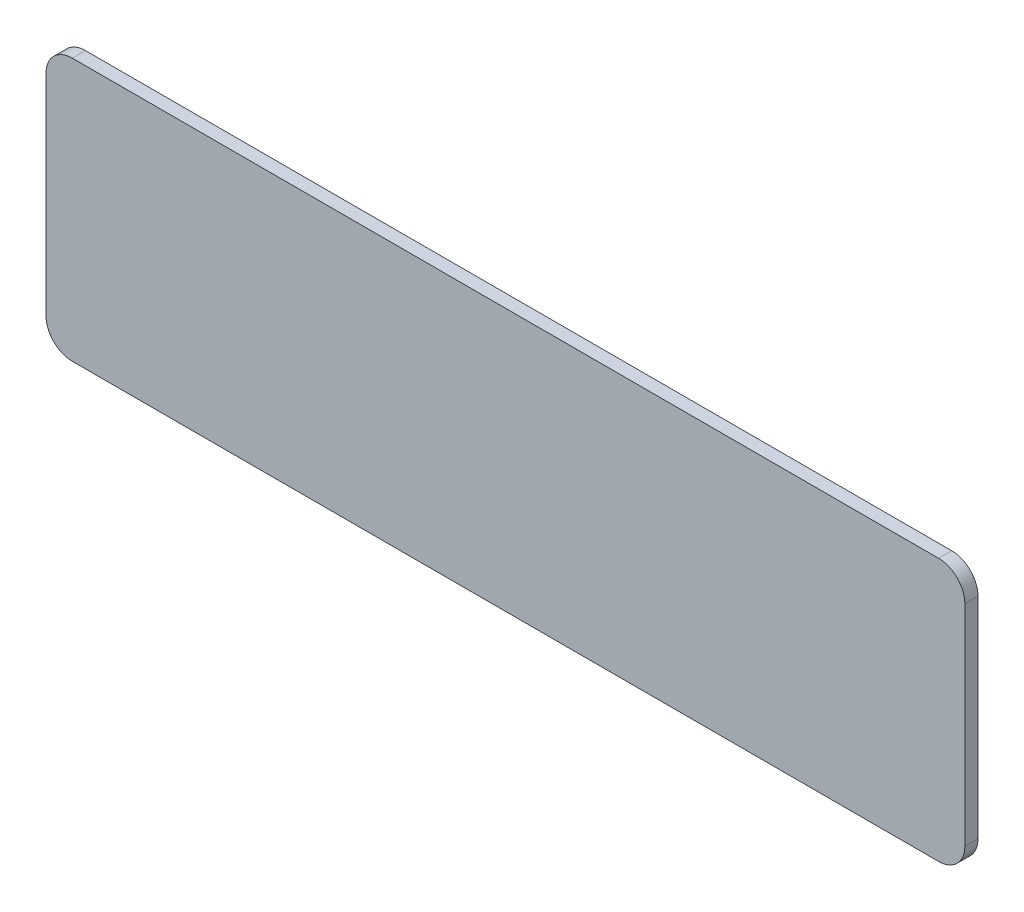
from build123d import *

# Parameters (mm, degrees)
BOSS_EXTRUDE1_DEPTH = 5


with BuildPart() as part:
    # Sketch1 → Boss-Extrude1 (new body)
    with BuildSketch(Plane.XY):
        with BuildLine():
            Line((-65.87, -50), (264.13, -50))
            ThreePointArc((264.13, -50), (271.201067812, -47.071067812), (274.13, -40))
            Line((274.13, -40), (274.13, 40))
            ThreePointArc((274.13, 40), (271.201067812, 47.071067812), (264.13, 50))
            Line((264.13, 50), (-65.87, 50))
            ThreePointArc((-65.87, 50), (-72.941067812, 47.071067812), (-75.87, 40))
            Line((-75.87, 40), (-75.87, -40))
            ThreePointArc((-75.87, -40), (-72.941067812, -47.071067812), (-65.87, -50))
        make_face()
    extrude(amount=-BOSS_EXTRUDE1_DEPTH)


solid = part.part
